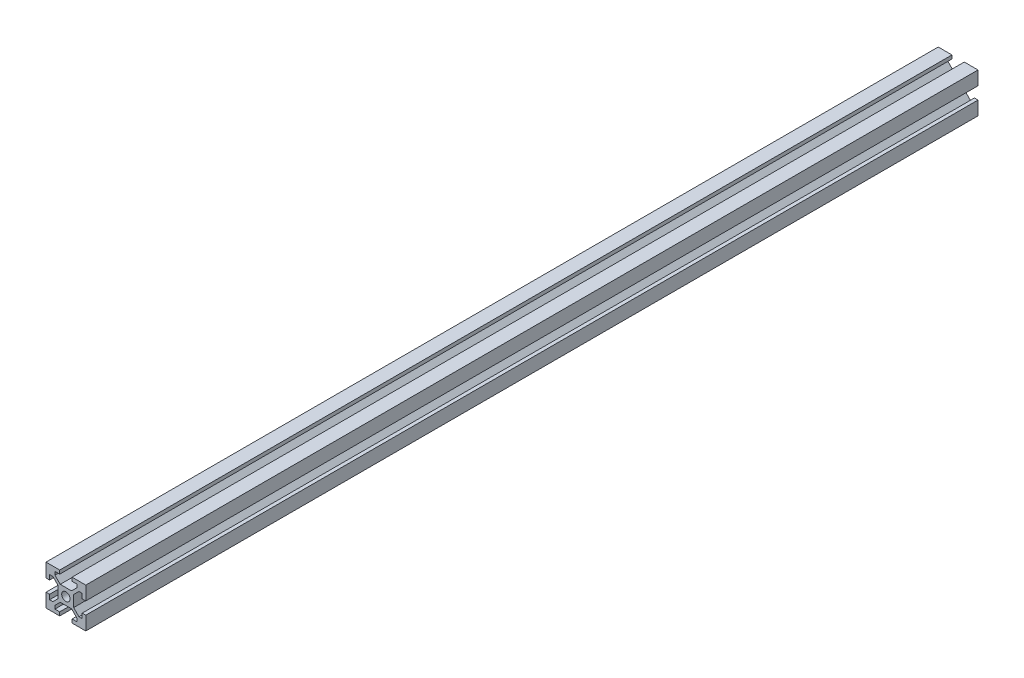
from build123d import *

# Parameters (mm, degrees)
BOSS_EXTRUDE1_DEPTH = 448.61
SKETCH2_R           = 2.1
CUT_EXTRUDE1_DEPTH  = 449.61
SKETCH3_R           = 2.1
CUT_EXTRUDE2_DEPTH  = 14.900660172


with BuildPart() as part:
    # Sketch1 → Boss-Extrude1 (new body)
    with BuildSketch(Plane.XY):
        Polygon((-3.1, 10), (-3.1, 8.200660172), (-5.5, 8.200660172), (-5.5, 6.560660172), (-2.84, 3.900660172), (2.84, 3.900660172), (5.5, 6.560660172), (5.5, 8.200660172), (3.1, 8.200660172), (3.1, 10), (10, 10), (10, 3.1), (8.200660172, 3.1), (8.200660172, 5.5), (6.560660172, 5.5), (3.900660172, 2.84), (3.900660172, -2.84), (6.560660172, -5.5), (8.200660172, -5.5), (8.200660172, -3.1), (10, -3.1), (10, -10), (3.1, -10), (3.1, -8.200660172), (5.5, -8.200660172), (5.5, -6.560660172), (2.84, -3.900660172), (-2.84, -3.900660172), (-5.5, -6.560660172), (-5.5, -8.200660172), (-3.1, -8.200660172), (-3.1, -10), (-10, -10), (-10, -3.1), (-8.200660172, -3.1), (-8.200660172, -5.5), (-6.560660172, -5.5), (-3.900660172, -2.84), (-3.900660172, 2.84), (-6.560660172, 5.5), (-8.200660172, 5.5), (-8.200660172, 3.1), (-10, 3.1), (-10, 10), align=None)
    extrude(amount=BOSS_EXTRUDE1_DEPTH)

    # Sketch2 → Cut-Extrude1 (cut, through all)
    with BuildSketch(Plane.XY.offset(448.61)):
        Circle(SKETCH2_R)
    extrude(amount=-CUT_EXTRUDE1_DEPTH, mode=Mode.SUBTRACT)

    # Sketch3 → Cut-Extrude2 (cut, through all)
    with BuildSketch(Plane(origin=(0, 3.900660172, 0), x_dir=(1, 0, 0), z_dir=(0, 1, 0))):
        with Locations((0, -224.305)):
            Circle(SKETCH3_R)
    extrude(amount=-CUT_EXTRUDE2_DEPTH, mode=Mode.SUBTRACT)


solid = part.part
